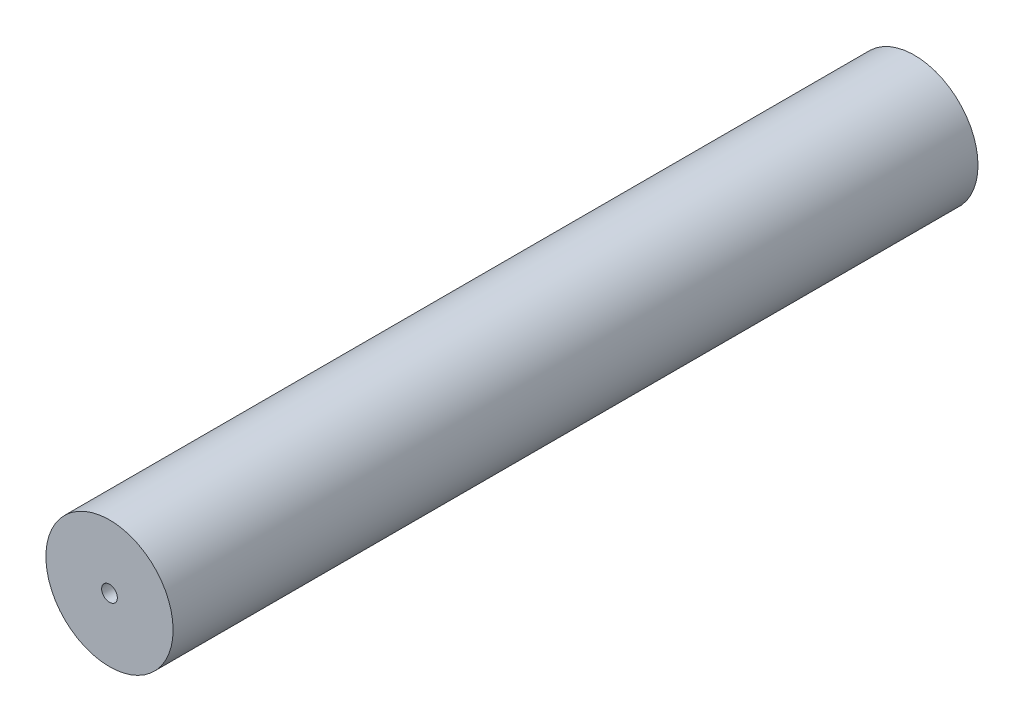
from build123d import *

# Parameters (mm, degrees)
SKETCH1_R           = 3.16103
BOSS_EXTRUDE1_DEPTH = 40
CUT_EXTRUDE1_REACH  = 42
SKETCH2_R           = 0.39


with BuildPart() as part:
    # Sketch1 → Boss-Extrude1 (new body)
    with BuildSketch(Plane.XY):
        Circle(SKETCH1_R)
    extrude(amount=BOSS_EXTRUDE1_DEPTH)

    # Sketch2 → Cut-Extrude1 (cut, up to next)
    with BuildSketch(Plane.XY.offset(40), mode=Mode.PRIVATE) as cut_extrude1_sk1:
        Circle(SKETCH2_R)
    cut_extrude1_tool1 = extrude(cut_extrude1_sk1.sketch, amount=-CUT_EXTRUDE1_REACH, mode=Mode.PRIVATE) & part.part
    add(cut_extrude1_tool1.solids().sort_by_distance((0, 0, 40))[0], mode=Mode.SUBTRACT)


solid = part.part
